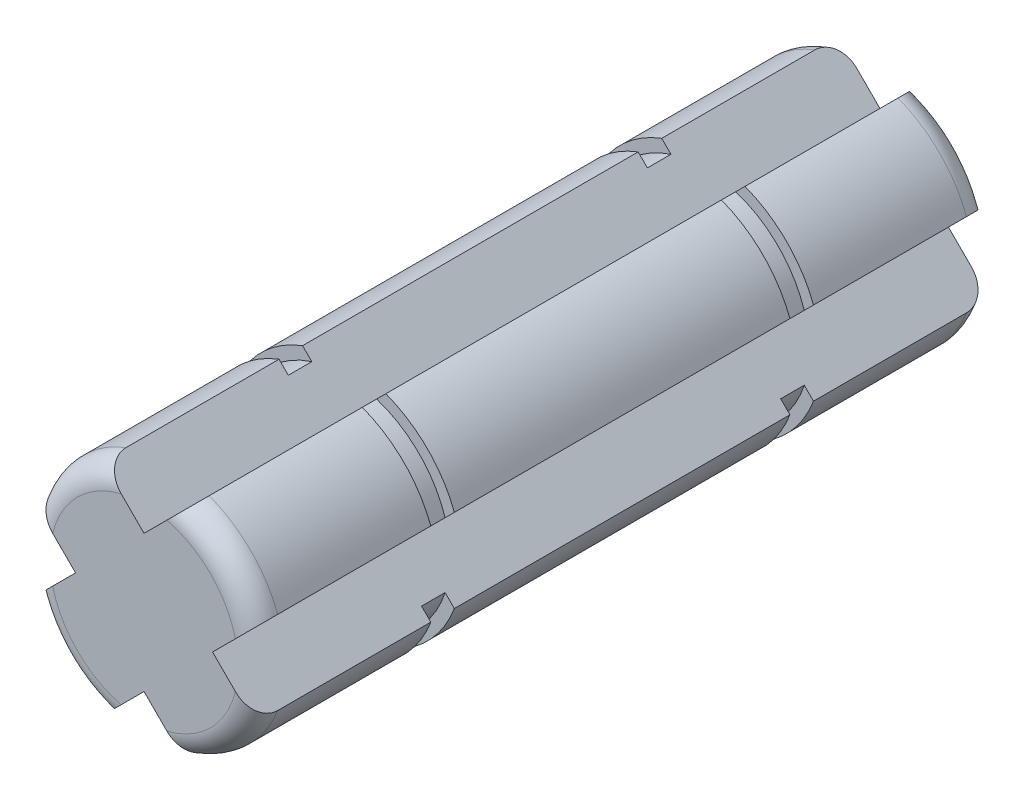
from build123d import *

# Parameters (mm, degrees)
BOSS_EXTRUDE1_DEPTH = 7.9375
SKETCH2_W           = 0.508
SKETCH2_H           = 0.254
FILLET3_R           = 0.508


with BuildPart() as part:
    # Sketch1 → Boss-Extrude1 (new body, symmetric)
    with BuildSketch(Plane.XY):
        with BuildLine():
            Line((-0.898025612, 2.375952441), (0, 1.477926828))
            Line((0, 1.477926828), (0.898025612, 2.375952441))
            ThreePointArc((0.898025612, 2.375952441), (1.796051224, 1.796051224), (2.375952441, 0.898025612))
            Line((2.375952441, 0.898025612), (1.477926828, 0))
            Line((1.477926828, 0), (2.375952441, -0.898025612))
            ThreePointArc((2.375952441, -0.898025612), (1.796051224, -1.796051224), (0.898025612, -2.375952441))
            Line((0.898025612, -2.375952441), (0, -1.477926828))
            Line((0, -1.477926828), (-0.898025612, -2.375952441))
            ThreePointArc((-0.898025612, -2.375952441), (-1.796051224, -1.796051224), (-2.375952441, -0.898025612))
            Line((-2.375952441, -0.898025612), (-1.477926828, 0))
            Line((-1.477926828, 0), (-2.375952441, 0.898025612))
            ThreePointArc((-2.375952441, 0.898025612), (-1.796051224, 1.796051224), (-0.898025612, 2.375952441))
        make_face()
    extrude(amount=BOSS_EXTRUDE1_DEPTH, both=True)

    # Sketch2 → Cut-Revolve2 (revolve, cut)
    with BuildSketch(Plane(origin=(0, 0, 0), x_dir=(0, 0, -1), z_dir=(1, 0, 0))):
        with Locations((-3.8735, 2.413)):
            Rectangle(SKETCH2_W, SKETCH2_H)
    cut_revolve2 = revolve(axis=Axis((0, 0, 0), (0, 0, 1)), mode=Mode.SUBTRACT)

    # Mirror1: Cut-Revolve2 across plane
    add(cut_revolve2.mirror(Plane.XY), mode=Mode.SUBTRACT)

    # Fillet3
    fillet3_edges = [part.edges().sort_by_distance(p)[0] for p in [
        (1.796051224, 1.796051224, -7.9375),
        (1.796051224, -1.796051224, -7.9375),
        (-1.796051224, -1.796051224, -7.9375),
        (-1.796051224, 1.796051224, -7.9375),
        (-1.796051224, -1.796051224, 7.9375),
        (1.796051224, -1.796051224, 7.9375),
        (1.796051224, 1.796051224, 7.9375),
        (-1.796051224, 1.796051224, 7.9375),
    ]]
    fillet(fillet3_edges, radius=FILLET3_R)


solid = part.part
